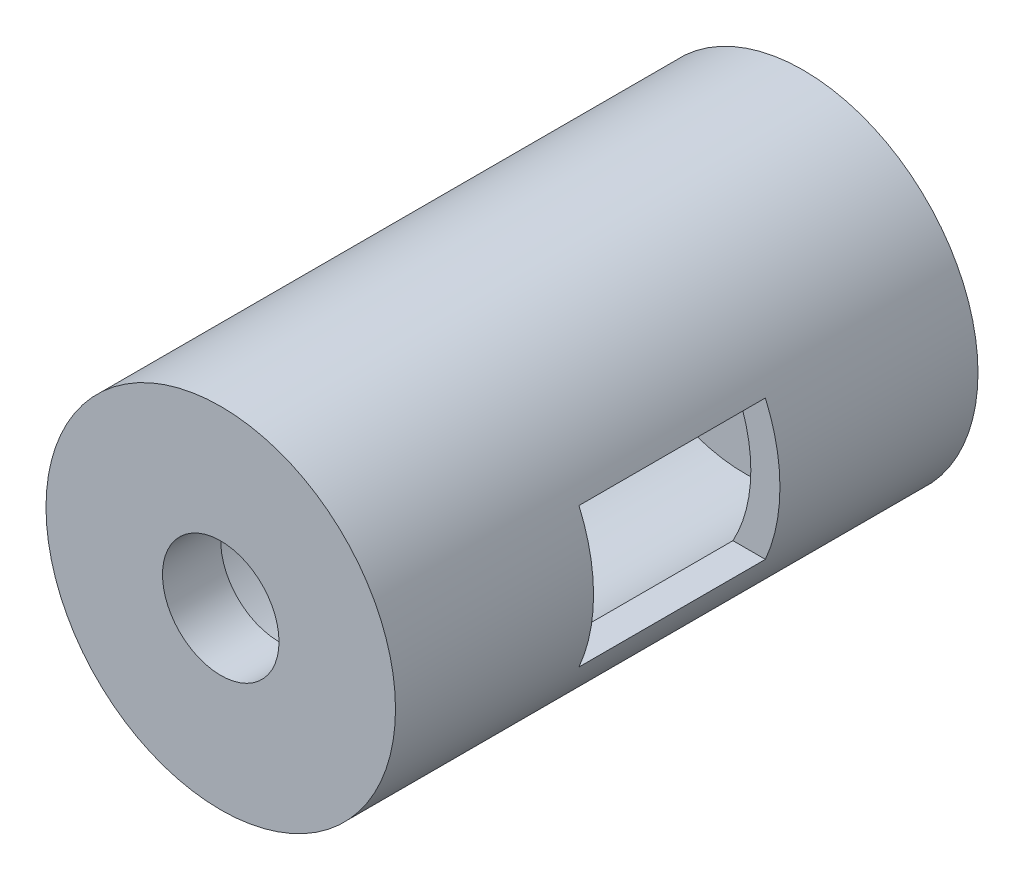
from build123d import *

# Parameters (mm, degrees)
SKETCH1_R           = 15
SKETCH1_R_2         = 12.5
BOSS_EXTRUDE1_DEPTH = 40
SKETCH2_R           = 15
BOSS_EXTRUDE2_DEPTH = 5
BOSS_EXTRUDE3_START = 5
SKETCH3_R           = 15
BOSS_EXTRUDE3_DEPTH = 5
SKETCH4_R           = 5
BOSS_EXTRUDE4_DEPTH = 160
SKETCH5_W           = 16
SKETCH5_H           = 12
CUT_EXTRUDE1_DEPTH  = 160


with BuildPart() as part:
    # Sketch1 → Boss-Extrude1 (new body)
    with BuildSketch(Plane.XY):
        with Locations((3.864023938, -0.112000694)):
            Circle(SKETCH1_R)
        with Locations((3.864023938, -0.112000694)):
            Circle(SKETCH1_R_2, mode=Mode.SUBTRACT)
    extrude(amount=BOSS_EXTRUDE1_DEPTH)

    # Sketch2 → Boss-Extrude2 (add)
    with BuildSketch(Plane.XY.offset(40)):
        with Locations((3.864023938, -0.112000694)):
            Circle(SKETCH2_R)
    extrude(amount=BOSS_EXTRUDE2_DEPTH)

    # Sketch3 → Boss-Extrude3 (add)
    with BuildSketch(Plane(origin=(0, 0, 0), x_dir=(-1, 0, 0), z_dir=(0, 0, -1)).offset(BOSS_EXTRUDE3_START)):
        with Locations((-3.864023938, -0.112000694)):
            Circle(SKETCH3_R)
    extrude(amount=-BOSS_EXTRUDE3_DEPTH)


with BuildPart() as body_2:
    # Sketch4 → Boss-Extrude4 (new body)
    with BuildSketch(Plane(origin=(0, 0, -5), x_dir=(-1, 0, 0), z_dir=(0, 0, -1))):
        with Locations((-3.864023938, -0.112000694)):
            Circle(SKETCH4_R)
    extrude(amount=-BOSS_EXTRUDE4_DEPTH)


with BuildPart() as part_1:
    add(part.part)

    # Combine1: cut body 2
    add(body_2.part, mode=Mode.SUBTRACT)

    # Sketch5 → Cut-Extrude1 (cut)
    with BuildSketch(Plane(origin=(0, 0, 0), x_dir=(0, 0, -1), z_dir=(1, 0, 0))):
        with Locations((-20, -0.112000694)):
            Rectangle(SKETCH5_W, SKETCH5_H)
    extrude(amount=CUT_EXTRUDE1_DEPTH, mode=Mode.SUBTRACT)


solid = part_1.part
